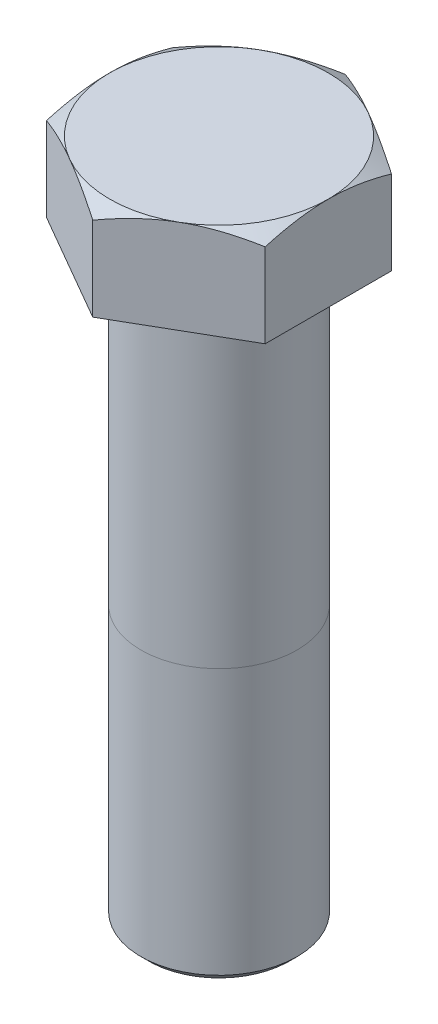
from build123d import *

# Parameters (mm, degrees)
BOSS_EXTRUDE1_DEPTH = 12
SKETCH2_OUTSIDE_W   = 80.454
SKETCH2_OUTSIDE_H   = 84.786
SKETCH2_OUTSIDE_R   = 14
CUT_EXTRUDE1_DEPTH  = 12
CUT_EXTRUDE1_TAPER  = 60
SKETCH3_R           = 10
BOSS_EXTRUDE2_DEPTH = 75
CHAMFER1_SIZE       = 1


with BuildPart() as part:
    # Sketch1 → Boss-Extrude1 (new body)
    with BuildSketch(Plane(origin=(0, 0, 0), x_dir=(1, 0, 0), z_dir=(0, 1, 0))):
        Polygon((14, 8.082903769), (0, 16.165807537), (-14, 8.082903769), (-14, -8.082903769), (0, -16.165807537), (14, -8.082903769), align=None)
    extrude(amount=BOSS_EXTRUDE1_DEPTH)

    # Sketch2 outside → Cut-Extrude1 (cut)
    with BuildSketch(Plane(origin=(0, 12, 0), x_dir=(1, 0, 0), z_dir=(0, 1, 0))):
        Rectangle(SKETCH2_OUTSIDE_W, SKETCH2_OUTSIDE_H)
        Circle(SKETCH2_OUTSIDE_R, mode=Mode.SUBTRACT)
    extrude(amount=-CUT_EXTRUDE1_DEPTH, taper=CUT_EXTRUDE1_TAPER, mode=Mode.SUBTRACT)

    # Sketch3 → Boss-Extrude2 (add)
    with BuildSketch(Plane.XZ):
        Circle(SKETCH3_R)
    extrude(amount=BOSS_EXTRUDE2_DEPTH)

    # Chamfer1
    chamfer1_edges = [part.edges().sort_by_distance(p)[0] for p in [
        (-10, -75, 0),
    ]]
    chamfer(chamfer1_edges, length=CHAMFER1_SIZE)


solid = part.part
